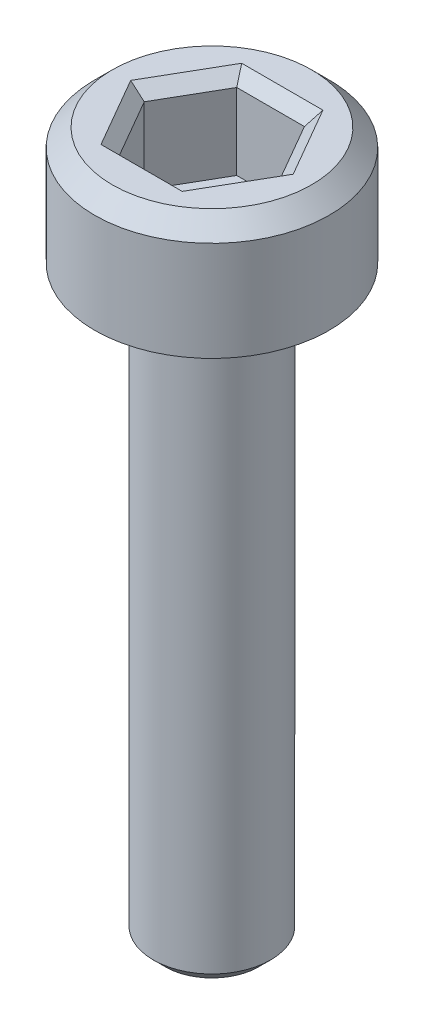
from build123d import *

# Parameters (mm, degrees)
SKETCH1_R           = 2
BOSS_EXTRUDE1_DEPTH = 2
CHAMFER1_SIZE       = 0.3
CUT_EXTRUDE1_DEPTH  = 1.5
CHAMFER2_SIZE       = 0.2
SKETCH3_R           = 1
BOSS_EXTRUDE2_DEPTH = 10
CHAMFER3_SIZE       = 0.2


with BuildPart() as part:
    # Sketch1 → Boss-Extrude1 (new body)
    with BuildSketch(Plane(origin=(0, 0, 0), x_dir=(1, 0, 0), z_dir=(0, 1, 0))):
        with Locations(Location((0, 0, 0), (0, 0, 270))):  # turned: the seam where the file's is
            Circle(SKETCH1_R)
    extrude(amount=BOSS_EXTRUDE1_DEPTH)

    # Chamfer1
    chamfer1_edges = [part.edges().sort_by_distance(p)[0] for p in [
        (0, 2, -2),
    ]]
    chamfer(chamfer1_edges, length=CHAMFER1_SIZE)

    # Sketch2 → Cut-Extrude1 (cut)
    with BuildSketch(Plane(origin=(0, 2, 0), x_dir=(1, 0, 0), z_dir=(0, 1, 0))):
        Polygon((1.154700538, 0), (0.577350269, 1), (-0.577350269, 1), (-1.154700538, 0), (-0.577350269, -1), (0.577350269, -1), align=None)
    extrude(amount=-CUT_EXTRUDE1_DEPTH, mode=Mode.SUBTRACT)

    # Chamfer2
    chamfer2_edges = [part.edges().sort_by_distance(p)[0] for p in [
        (0.866025404, 2, 0.5),
        (0.866025404, 2, -0.5),
        (0, 2, -1),
        (-0.866025404, 2, -0.5),
        (-0.866025404, 2, 0.5),
        (0, 2, 1),
    ]]
    chamfer(chamfer2_edges, length=CHAMFER2_SIZE)

    # Sketch3 → Boss-Extrude2 (add)
    with BuildSketch(Plane.XZ):
        with Locations(Location((0, 0, 0), (0, 0, 90))):  # turned: the seam where the file's is
            Circle(SKETCH3_R)
    extrude(amount=BOSS_EXTRUDE2_DEPTH)

    # Chamfer3
    chamfer3_edges = [part.edges().sort_by_distance(p)[0] for p in [
        (0, -10, -1),
    ]]
    chamfer(chamfer3_edges, length=CHAMFER3_SIZE)


solid = part.part
